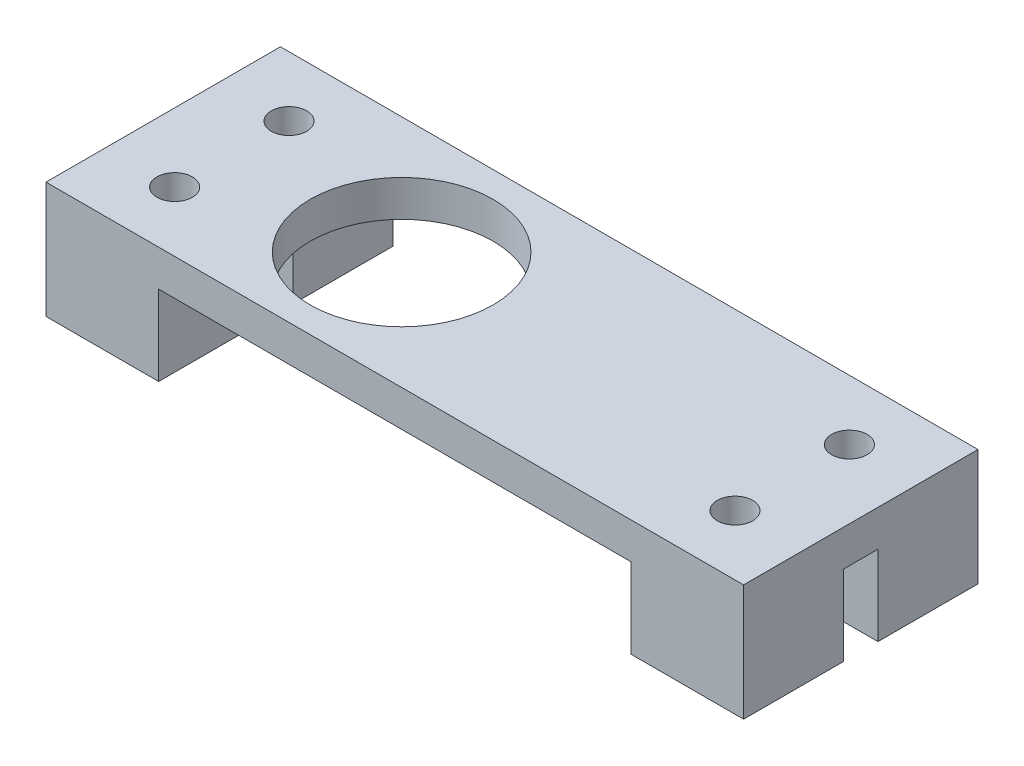
from build123d import *

# Parameters (mm, degrees)
SKETCH2_W           = 61
SKETCH2_H           = 20.5
SKETCH2_R           = 8
SKETCH2_R_2         = 1.55
BOSS_EXTRUDE1_DEPTH = 3.175
SKETCH3_W           = 9.85
SKETCH3_H           = 8.75
SKETCH3_R           = 1.55
BOSS_EXTRUDE2_DEPTH = 7


with BuildPart() as part:
    # Sketch2 → Boss-Extrude1 (new body)
    with BuildSketch(Plane(origin=(0, 0, 0), x_dir=(1, 0, 0), z_dir=(0, 1, 0))):
        Rectangle(SKETCH2_W, SKETCH2_H)
        with Locations((-9.65, 0)):
            Circle(SKETCH2_R, mode=Mode.SUBTRACT)
        with Locations((-24.5, 5)):
            Circle(SKETCH2_R_2, mode=Mode.SUBTRACT)
        with Locations((-24.5, -5)):
            Circle(SKETCH2_R_2, mode=Mode.SUBTRACT)
        with Locations((24.5, 5)):
            Circle(SKETCH2_R_2, mode=Mode.SUBTRACT)
        with Locations((24.5, -5)):
            Circle(SKETCH2_R_2, mode=Mode.SUBTRACT)
    extrude(amount=BOSS_EXTRUDE1_DEPTH)

    # Sketch3 → Boss-Extrude2 (add)
    with BuildSketch(Plane.XZ):
        with Locations((-25.575, 5.875)):
            Rectangle(SKETCH3_W, SKETCH3_H)
        with Locations((-24.5, 5)):
            Circle(SKETCH3_R, mode=Mode.SUBTRACT)
        with Locations((-25.575, -5.875)):
            Rectangle(SKETCH3_W, SKETCH3_H)
        with Locations((-24.5, -5)):
            Circle(SKETCH3_R, mode=Mode.SUBTRACT)
        with Locations((25.575, 5.875)):
            Rectangle(SKETCH3_W, SKETCH3_H)
        with Locations((24.5, 5)):
            Circle(SKETCH3_R, mode=Mode.SUBTRACT)
        with Locations((25.575, -5.875)):
            Rectangle(SKETCH3_W, SKETCH3_H)
        with Locations((24.5, -5)):
            Circle(SKETCH3_R, mode=Mode.SUBTRACT)
    extrude(amount=BOSS_EXTRUDE2_DEPTH)


solid = part.part
